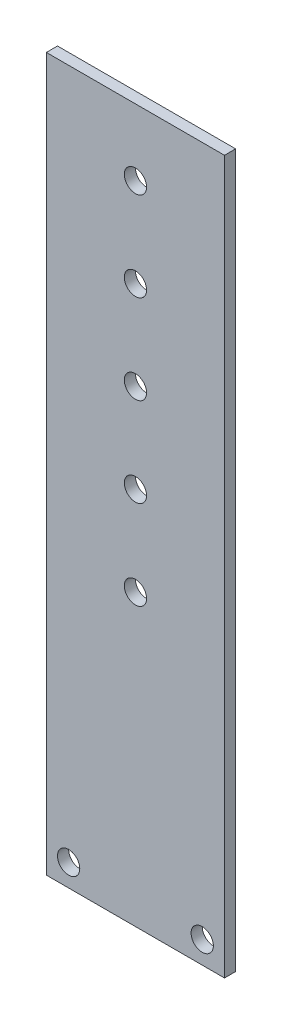
from build123d import *

# Parameters (mm, degrees)
SKETCH1_W           = 50.8
SKETCH1_H           = 203.2
SKETCH1_R           = 3.175
BOSS_EXTRUDE1_DEPTH = 3.175


with BuildPart() as part:
    # Sketch1 → Boss-Extrude1 (new body)
    with BuildSketch(Plane.XY):
        with Locations((25.4, 101.6)):
            Rectangle(SKETCH1_W, SKETCH1_H)
        with Locations((6.35, 6.35)):
            Circle(SKETCH1_R, mode=Mode.SUBTRACT)
        with Locations((44.45, 6.35)):
            Circle(SKETCH1_R, mode=Mode.SUBTRACT)
        with Locations((25.4, 184.2)):
            Circle(SKETCH1_R, mode=Mode.SUBTRACT)
        with Locations((25.4, 158.8)):
            Circle(SKETCH1_R, mode=Mode.SUBTRACT)
        with Locations((25.4, 133.4)):
            Circle(SKETCH1_R, mode=Mode.SUBTRACT)
        with Locations((25.4, 108)):
            Circle(SKETCH1_R, mode=Mode.SUBTRACT)
        with Locations((25.4, 82.6)):
            Circle(SKETCH1_R, mode=Mode.SUBTRACT)
    extrude(amount=BOSS_EXTRUDE1_DEPTH)


solid = part.part
